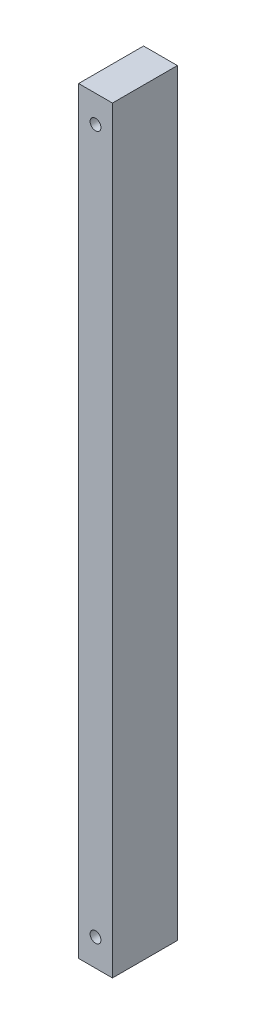
from build123d import *

# Parameters (mm, degrees)
SKETCH1_W           = 38.1
SKETCH1_H           = 444.5
BOSS_EXTRUDE1_DEPTH = 19.84375
SKETCH2_R           = 3.175
CUT_EXTRUDE1_DEPTH  = 39.1


with BuildPart() as part:
    # Sketch1 → Boss-Extrude1 (new body)
    with BuildSketch(Plane(origin=(0, 0, 0), x_dir=(0, 0, -1), z_dir=(1, 0, 0))):
        with Locations((19.05, 222.25)):
            Rectangle(SKETCH1_W, SKETCH1_H)
    extrude(amount=BOSS_EXTRUDE1_DEPTH)

    # Sketch2 → Cut-Extrude1 (cut, through all)
    with BuildSketch(Plane.XY):
        with Locations((9.921875, 15.875)):
            Circle(SKETCH2_R)
        with Locations((9.921875, 428.625)):
            Circle(SKETCH2_R)
    extrude(amount=-CUT_EXTRUDE1_DEPTH, mode=Mode.SUBTRACT)


solid = part.part
